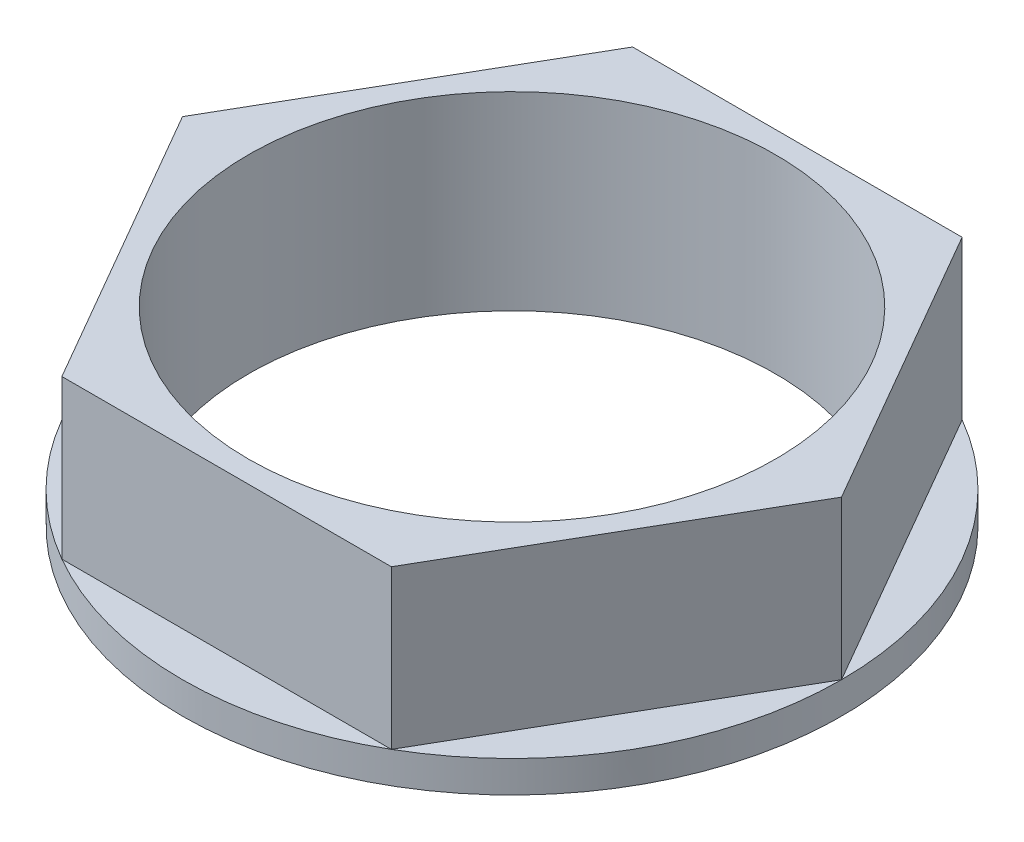
from build123d import *

# Parameters (mm, degrees)
SKETCH1_R           = 7.9375
BOSS_EXTRUDE1_DEPTH = 0.381
BOSS_EXTRUDE2_DEPTH = 3.81
SKETCH3_R           = 6.35
CUT_EXTRUDE1_DEPTH  = 5.572


with BuildPart() as part:
    # Sketch1 → Boss-Extrude1 (new body, symmetric)
    with BuildSketch(Plane(origin=(0, 0, 0), x_dir=(1, 0, 0), z_dir=(0, 1, 0))):
        Circle(SKETCH1_R)
    extrude(amount=BOSS_EXTRUDE1_DEPTH, both=True)

    # Sketch2 → Boss-Extrude2 (add)
    with BuildSketch(Plane(origin=(0, 0.381, 0), x_dir=(1, 0, 0), z_dir=(0, 1, 0))):
        Polygon((-3.96875, -6.874076643), (3.96875, -6.874076643), (7.9375, 0), (3.96875, 6.874076643), (-3.96875, 6.874076643), (-7.9375, 0), align=None)
    extrude(amount=BOSS_EXTRUDE2_DEPTH)

    # Sketch3 → Cut-Extrude1 (cut, through all)
    with BuildSketch(Plane(origin=(0, 4.191, 0), x_dir=(1, 0, 0), z_dir=(0, 1, 0))):
        Circle(SKETCH3_R)
    extrude(amount=-CUT_EXTRUDE1_DEPTH, mode=Mode.SUBTRACT)


solid = part.part
